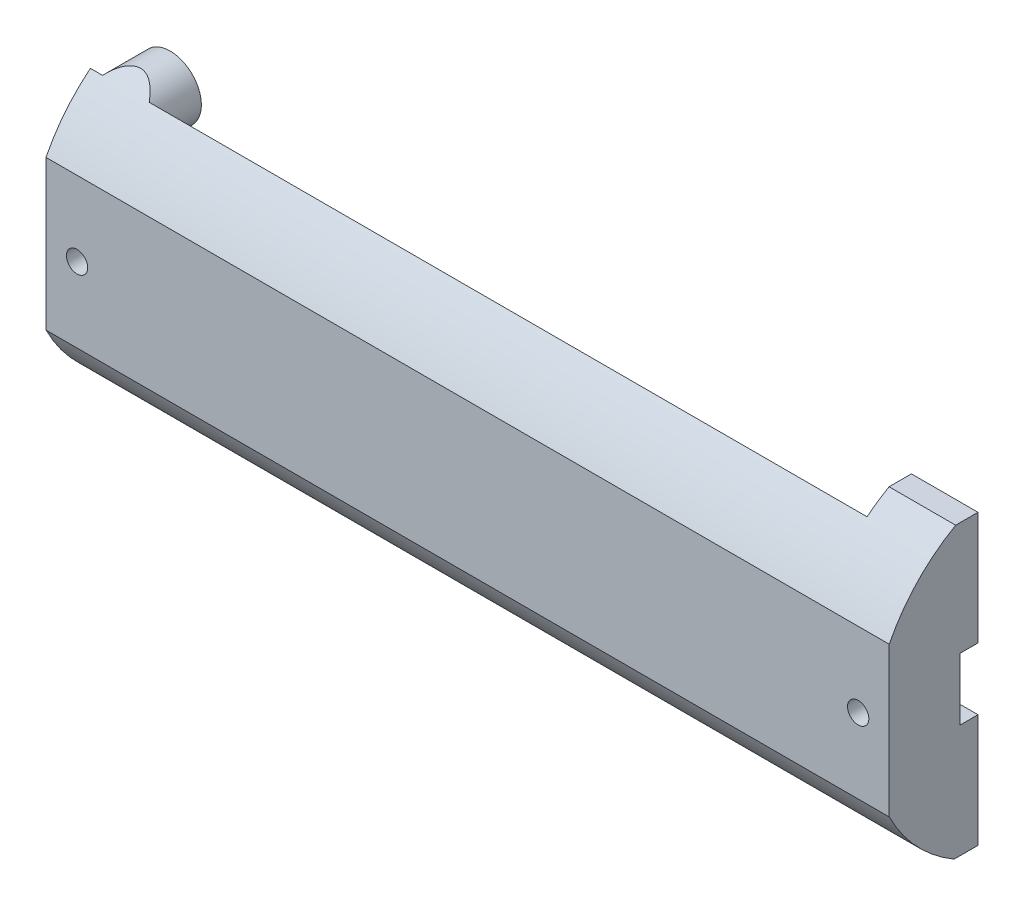
from build123d import *

# Parameters (mm, degrees)
SKETCH1_R             = 4
SKETCH1_R_2           = 1.5
BOSS_EXTRUDE1_DEPTH   = 5
BOSS_EXTRUDE1_2_DEPTH = 5
BOSS_EXTRUDE1_3_DEPTH = 5
BOSS_EXTRUDE1_4_DEPTH = 5
SKETCH2_W             = 95
SKETCH2_H             = 32.5
BOSS_EXTRUDE2_DEPTH   = 10
SKETCH3_W             = 45
SKETCH3_H             = 14.2
CUT_EXTRUDE1_DEPTH    = 9
SKETCH4_W             = 5
SKETCH4_H             = 14.2
SKETCH4_W_2           = 45
CUT_EXTRUDE2_DEPTH    = 4
SKETCH5_R             = 1.4
SKETCH5_R_2           = 1.6
CUT_EXTRUDE3_DEPTH    = 5
BOSS_EXTRUDE3_DEPTH   = 5
CUT_EXTRUDE5_DEPTH    = 96
SKETCH9_W             = 7
SKETCH9_H             = 7
CUT_EXTRUDE6_DEPTH    = 96
SKETCH10_R            = 1.2
CUT_EXTRUDE7_DEPTH    = 16
SKETCH12_R            = 1.5
CUT_EXTRUDE9_DEPTH    = 10
SKETCH13_W            = 95
SKETCH13_H            = 32.5
CUT_EXTRUDE10_DEPTH   = 5
SKETCH14_R            = 3.5
CUT_EXTRUDE11_DEPTH   = 5
SKETCH15_W            = 45
SKETCH15_H            = 14.2
CUT_EXTRUDE12_DEPTH   = 0.5
SKETCH16_R            = 1.4
SKETCH16_R_2          = 1.6
SKETCH16_W            = 45
SKETCH16_H            = 14.2
CUT_EXTRUDE13_DEPTH   = 2


with BuildPart() as part:
    # Sketch1 → Boss-Extrude1 (new body)
    with BuildSketch(Plane.XY):
        with Locations((-43.5, -12.25)):
            Circle(SKETCH1_R)
        with Locations((-43.5, -12.25)):
            Circle(SKETCH1_R_2, mode=Mode.SUBTRACT)
    extrude(amount=BOSS_EXTRUDE1_DEPTH)



with BuildPart() as body_2:
    # Sketch1 → Boss-Extrude1 2 (new body)
    with BuildSketch(Plane.XY):
        with Locations((-43.5, 12.25)):
            Circle(SKETCH1_R)
        with Locations((-43.5, 12.25)):
            Circle(SKETCH1_R_2, mode=Mode.SUBTRACT)
    extrude(amount=BOSS_EXTRUDE1_2_DEPTH)


with BuildPart() as body_3:
    # Sketch1 → Boss-Extrude1 3 (new body)
    with BuildSketch(Plane.XY):
        with Locations((43.5, -12.25)):
            Circle(SKETCH1_R)
        with Locations((43.5, -12.25)):
            Circle(SKETCH1_R_2, mode=Mode.SUBTRACT)
    extrude(amount=BOSS_EXTRUDE1_3_DEPTH)


with BuildPart() as body_4:
    # Sketch1 → Boss-Extrude1 4 (new body)
    with BuildSketch(Plane.XY):
        with Locations((43.5, 12.25)):
            Circle(SKETCH1_R)
        with Locations((43.5, 12.25)):
            Circle(SKETCH1_R_2, mode=Mode.SUBTRACT)
    extrude(amount=BOSS_EXTRUDE1_4_DEPTH)


with BuildPart() as part_1:
    add(part.part)

    add(body_2.part)  # Boss-Extrude2 merges body 2

    add(body_3.part)  # Boss-Extrude2 merges body 3

    add(body_4.part)  # Boss-Extrude2 merges body 4
    # Sketch2 → Boss-Extrude2 (add)
    with BuildSketch(Plane.XY.offset(5)):
        Rectangle(SKETCH2_W, SKETCH2_H)
    extrude(amount=BOSS_EXTRUDE2_DEPTH)

    # Sketch3 → Cut-Extrude1 (cut)
    with BuildSketch(Plane(origin=(0, 0, 5), x_dir=(-1, 0, 0), z_dir=(0, 0, -1))):
        Rectangle(SKETCH3_W, SKETCH3_H)
    extrude(amount=-CUT_EXTRUDE1_DEPTH, mode=Mode.SUBTRACT)

    # Sketch4 → Cut-Extrude2 (cut)
    with BuildSketch(Plane(origin=(0, 0, 5), x_dir=(-1, 0, 0), z_dir=(0, 0, -1))):
        with Locations((-25, 0)):
            Rectangle(SKETCH4_W, SKETCH4_H)
        Rectangle(SKETCH4_W_2, SKETCH4_H)
        with Locations((25, 0)):
            Rectangle(SKETCH4_W, SKETCH4_H)
    extrude(amount=-CUT_EXTRUDE2_DEPTH, mode=Mode.SUBTRACT)

    # Sketch5 → Cut-Extrude3 (cut)
    with BuildSketch(Plane(origin=(0, 0, 9), x_dir=(-1, 0, 0), z_dir=(0, 0, -1))):
        with Locations((-24.8, -0.2)):
            Circle(SKETCH5_R)
        with Locations((24.8, -0.2)):
            Circle(SKETCH5_R_2)
    extrude(amount=-CUT_EXTRUDE3_DEPTH, mode=Mode.SUBTRACT)

    # Sketch6 → Boss-Extrude3 (add)
    with BuildSketch(Plane(origin=(0, 0, 5), x_dir=(-1, 0, 0), z_dir=(0, 0, -1))):
        with BuildLine():
            ThreePointArc((47.5, 12.25), (43.5, 8.25), (39.5, 12.25))
            Line((39.5, 12.25), (39.5, -12.25))
            ThreePointArc((39.5, -12.25), (43.5, -8.25), (47.5, -12.25))
            Line((47.5, -12.25), (47.5, 12.25))
        make_face()
        with BuildLine():
            ThreePointArc((-39.5, 12.25), (-43.5, 8.25), (-47.5, 12.25))
            Line((-47.5, 12.25), (-47.5, -12.25))
            ThreePointArc((-47.5, -12.25), (-43.5, -8.25), (-39.5, -12.25))
            Line((-39.5, -12.25), (-39.5, 12.25))
        make_face()
    extrude(amount=BOSS_EXTRUDE3_DEPTH)

    # Sketch8 → Cut-Extrude5 (cut, through all)
    with BuildSketch(Plane(origin=(47.5, 0, 0), x_dir=(0, 0, -1), z_dir=(1, 0, 0))):
        with BuildLine():
            ThreePointArc((-15, 8.377014021), (-11.841659381, 12.867099577), (-7.518238456, 16.25))
            Line((-7.518238456, 16.25), (-15, 16.25))
            Line((-15, 16.25), (-15, 8.377014021))
        make_face()
        with BuildLine():
            Line((-15, -16.25), (-7.688934819, -16.25))
            ThreePointArc((-7.688934819, -16.25), (-11.909309532, -12.893789895), (-15, -8.475267356))
            Line((-15, -8.475267356), (-15, -16.25))
        make_face()
    extrude(amount=-CUT_EXTRUDE5_DEPTH, mode=Mode.SUBTRACT)

    # Sketch9 → Cut-Extrude6 (cut, through all)
    with BuildSketch(Plane.ZY.offset(47.5)):
        with Locations((3.5, 0)):
            Rectangle(SKETCH9_W, SKETCH9_H)
    extrude(amount=-CUT_EXTRUDE6_DEPTH, mode=Mode.SUBTRACT)

    # Sketch10 → Cut-Extrude7 (cut, through all)
    with BuildSketch(Plane.XY.offset(15)):
        with Locations((-44, -0.049126667)):
            Circle(SKETCH10_R)
        with Locations((44, -0.049126667)):
            Circle(SKETCH10_R)
    extrude(amount=-CUT_EXTRUDE7_DEPTH, mode=Mode.SUBTRACT)

    # Sketch12 → Cut-Extrude9 (cut)
    with BuildSketch(Plane(origin=(0, 0, 0), x_dir=(-1, 0, 0), z_dir=(0, 0, -1))):
        with Locations((-43.5, 12.25)):
            Circle(SKETCH12_R)
        with Locations((-43.5, -12.25)):
            Circle(SKETCH12_R)
        with Locations((43.5, 12.25)):
            Circle(SKETCH12_R)
        with Locations((43.5, -12.25)):
            Circle(SKETCH12_R)
    extrude(amount=-CUT_EXTRUDE9_DEPTH, mode=Mode.SUBTRACT)

    # Sketch13 → Cut-Extrude10 (cut)
    with BuildSketch(Plane(origin=(0, 0, 0), x_dir=(-1, 0, 0), z_dir=(0, 0, -1))):
        Rectangle(SKETCH13_W, SKETCH13_H)
    extrude(amount=-CUT_EXTRUDE10_DEPTH, mode=Mode.SUBTRACT)

    # Sketch14 → Cut-Extrude11 (cut)
    with BuildSketch(Plane(origin=(0, 0, 5), x_dir=(-1, 0, 0), z_dir=(0, 0, -1))):
        Polygon((-40, 16.25), (-40, -3.5), (-27.5, -3.5), (-27.5, -7.1), (27.5, -7.1), (27.5, -3.5), (47.5, -3.5), (47.5, 16.25), align=None)
        with Locations((43.5, 12.25)):
            Circle(SKETCH14_R, mode=Mode.SUBTRACT)
        Polygon((-40, -3.5), (-40, -12.25), (-40, -16.25), (47.5, -16.25), (47.5, -3.5), (27.5, -3.5), (27.5, -7.1), (-27.5, -7.1), (-27.5, -3.5), align=None)
        with Locations((43.5, -12.25)):
            Circle(SKETCH14_R, mode=Mode.SUBTRACT)
    extrude(amount=-CUT_EXTRUDE11_DEPTH, mode=Mode.SUBTRACT)

    # Sketch15 → Cut-Extrude12 (cut)
    with BuildSketch(Plane(origin=(0, 0, 14), x_dir=(-1, 0, 0), z_dir=(0, 0, -1))):
        Rectangle(SKETCH15_W, SKETCH15_H)
    extrude(amount=-CUT_EXTRUDE12_DEPTH, mode=Mode.SUBTRACT)

    # Sketch16 → Cut-Extrude13 (cut)
    with BuildSketch(Plane(origin=(0, 0, 10), x_dir=(-1, 0, 0), z_dir=(0, 0, -1))):
        Polygon((-27.5, 7.3), (-27.5, 7.1), (-27.5, -7.3), (27.5, -7.3), (27.5, -7.1), (27.5, 7.3), align=None)
        with Locations((-24.8, -0.2)):
            Circle(SKETCH16_R, mode=Mode.SUBTRACT)
        with Locations((24.8, -0.2)):
            Circle(SKETCH16_R_2, mode=Mode.SUBTRACT)
        Rectangle(SKETCH16_W, SKETCH16_H, mode=Mode.SUBTRACT)
        Rectangle(SKETCH16_W, SKETCH16_H)
    extrude(amount=-CUT_EXTRUDE13_DEPTH, mode=Mode.SUBTRACT)


solid = part_1.part
